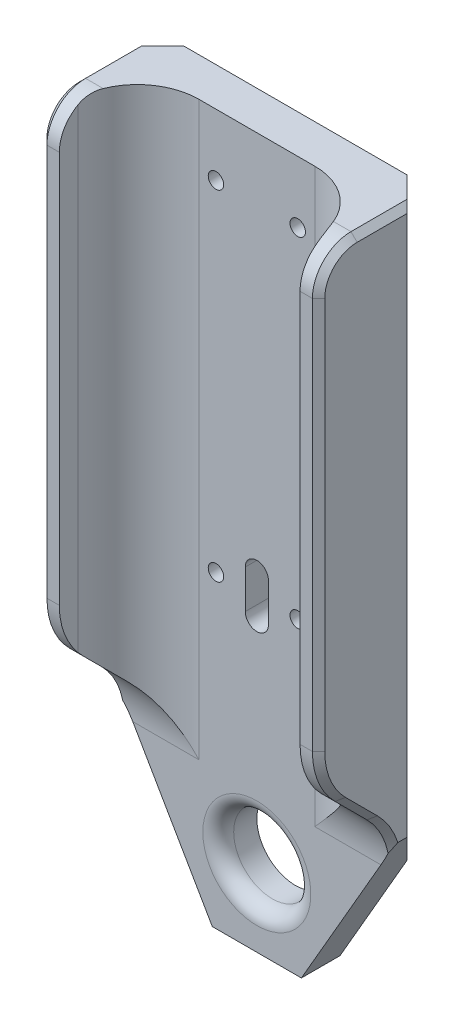
from build123d import *

# Parameters (mm, degrees)
BOSS_EXTRUDE1_DEPTH     = 60
BOSS_EXTRUDE2_START     = -32
BOSS_EXTRUDE2_DEPTH     = 32
CUT_EXTRUDE1_DEPTH      = 65.413446422
CUT_EXTRUDE1_DEPTH_BACK = 65.413446422
SKETCH3_R               = 5
CUT_EXTRUDE2_DEPTH      = 64.435731886
FILLET1_R               = 2
CUT_EXTRUDE6_DEPTH      = 65.413446422
CUT_EXTRUDE6_DEPTH_BACK = 65.413446422
SKETCH4_R               = 1
CUT_EXTRUDE7_DEPTH      = 65.413446422
FILLET2_R               = 5
FILLET3_R               = 10
FILLET4_R               = 10
CHAMFER2_SIZE           = 0.8


with BuildPart() as part:
    # Sketch1 → Boss-Extrude1 (new body)
    with BuildSketch(Plane(origin=(0, 0, 0), x_dir=(1, 0, 0), z_dir=(0, 1, 0))):
        with BuildLine():
            Line((-6.630434783, 0), (6.630434783, 0))
            Line((6.630434783, 0), (14.467023689, 0))
            Line((14.467023689, 0), (18.002557594, -3.535533906))
            Line((18.002557594, -3.535533906), (18.002557594, -15))
            Line((18.002557594, -15), (15.602557594, -15))
            Line((15.602557594, -15), (15.5, -12.651044901))
            ThreePointArc((15.5, -12.651044901), (13.039718674, -7.221088304), (7.507614227, -5))
            Line((7.507614227, -5), (-7.507614227, -5))
            ThreePointArc((-7.507614227, -5), (-13.039718674, -7.221088304), (-15.5, -12.651044901))
            Line((-15.5, -12.651044901), (-15.602557594, -15))
            Line((-15.602557594, -15), (-18.002557594, -15))
            Line((-18.002557594, -15), (-18.002557594, -3.535533906))
            Line((-18.002557594, -3.535533906), (-14.467023689, 0))
            Line((-14.467023689, 0), (-6.630434783, 0))
        make_face()
    extrude(amount=BOSS_EXTRUDE1_DEPTH)

    # Sketch1_2 → Boss-Extrude2 (add)
    with BuildSketch(Plane(origin=(0, 0, 0), x_dir=(1, 0, 0), z_dir=(0, 1, 0)).offset(BOSS_EXTRUDE2_START)):
        with BuildLine():
            Line((-6.630434783, 0), (6.630434783, 0))
            Line((6.630434783, 0), (14.467023689, 0))
            Line((14.467023689, 0), (18.002557594, -3.535533906))
            Line((18.002557594, -3.535533906), (18.002557594, -15))
            Line((18.002557594, -15), (15.602557594, -15))
            Line((15.602557594, -15), (15.5, -12.651044901))
            ThreePointArc((15.5, -12.651044901), (13.039718674, -7.221088304), (7.507614227, -5))
            Line((7.507614227, -5), (-7.507614227, -5))
            ThreePointArc((-7.507614227, -5), (-13.039718674, -7.221088304), (-15.5, -12.651044901))
            Line((-15.5, -12.651044901), (-15.602557594, -15))
            Line((-15.602557594, -15), (-18.002557594, -15))
            Line((-18.002557594, -15), (-18.002557594, -3.535533906))
            Line((-18.002557594, -3.535533906), (-14.467023689, 0))
            Line((-14.467023689, 0), (-6.630434783, 0))
        make_face()
    extrude(amount=BOSS_EXTRUDE2_DEPTH)

    # Sketch2 → Cut-Extrude1 (cut, two sides: drawn at the far end of the back side and taken through both)
    with BuildSketch(Plane(origin=(0, 0, 0), x_dir=(0, 0, -1), z_dir=(1, 0, 0)).offset(-CUT_EXTRUDE1_DEPTH_BACK)):
        Polygon((-15, 0), (-5, -10), (-5, -32), (-15, -32), align=None)
    extrude(amount=CUT_EXTRUDE1_DEPTH + CUT_EXTRUDE1_DEPTH_BACK, mode=Mode.SUBTRACT)

    # Sketch3 → Cut-Extrude2 (cut, through all)
    with BuildSketch(Plane.XY.offset(5)):
        with Locations((0, -22)):
            Circle(SKETCH3_R)
        Polygon((18.002557594, -10.81865558), (18.002557594, -32), (5.773502692, -32), align=None)
        Polygon((-18.002557594, -32), (-5.773502692, -32), (-18.002557594, -10.81865558), align=None)
    extrude(amount=-CUT_EXTRUDE2_DEPTH, mode=Mode.SUBTRACT)

    # Fillet1
    fillet1_edges = [part.edges().sort_by_distance(p)[0] for p in [
        (-5, -22, 5),
    ]]
    fillet(fillet1_edges, radius=FILLET1_R)

    # Sketch4 → Cut-Extrude6 (cut, two sides: drawn at the far end of the back side and taken through both)
    with BuildSketch(Plane.XY.offset(-CUT_EXTRUDE6_DEPTH_BACK)):
        with Locations((5.3, 52)):
            Circle(SKETCH4_R)
        with Locations((-5.3, 52)):
            Circle(SKETCH4_R)
        with Locations((-5.3, 8)):
            Circle(SKETCH4_R)
        with Locations((5.3, 8)):
            Circle(SKETCH4_R)
    extrude(amount=CUT_EXTRUDE6_DEPTH + CUT_EXTRUDE6_DEPTH_BACK, mode=Mode.SUBTRACT)

    # Sketch5 → Cut-Extrude7 (cut, through all)
    with BuildSketch(Plane.XY):
        with BuildLine():
            Line((-1.5, 5.5), (-1.5, 10.5))
            ThreePointArc((-1.5, 10.5), (0, 12), (1.5, 10.5))
            Line((1.5, 10.5), (1.5, 5.5))
            ThreePointArc((1.5, 5.5), (0, 4), (-1.5, 5.5))
        make_face()
    extrude(amount=CUT_EXTRUDE7_DEPTH, mode=Mode.SUBTRACT)

    # Fillet2
    fillet2_edges = [part.edges().sort_by_distance(p)[0] for p in [
        (16.802557594, 60, 15),
        (-16.802557594, 60, 15),
    ]]
    fillet(fillet2_edges, radius=FILLET2_R)

    # Fillet3
    fillet3_edges = [part.edges().sort_by_distance(p)[0] for p in [
        (-16.802557594, 0, 15),
        (16.802557594, 0, 15),
    ]]
    fillet(fillet3_edges, radius=FILLET3_R)

    # Fillet4
    fillet4_edges = [part.edges().sort_by_distance(p)[0] for p in [
        (-12.755085911, -10, 5),
        (12.755085911, -10, 5),
    ]]
    fillet(fillet4_edges, radius=FILLET4_R)

    # Chamfer2
    chamfer2_edges = [part.edges().sort_by_distance(p)[0] for p in [
        (18.002557594, -8.812534616, 6.538596269),
        (18.002557594, 60, 6.767766953),
        (18.002557594, -5, 10),
        (18.002557594, 58.535533906, 13.535533906),
        (18.002557594, 0.3153013, 14.238795325),
        (18.002557594, 29.571067812, 15),
        (-18.002557594, -8.812534616, 6.538596269),
        (-18.002557594, 60, 6.767766953),
        (-18.002557594, -5, 10),
        (-18.002557594, 58.535533906, 13.535533906),
        (-18.002557594, 0.3153013, 14.238795325),
        (-18.002557594, 29.571067812, 15),
    ]]
    chamfer(chamfer2_edges, length=CHAMFER2_SIZE)


solid = part.part
